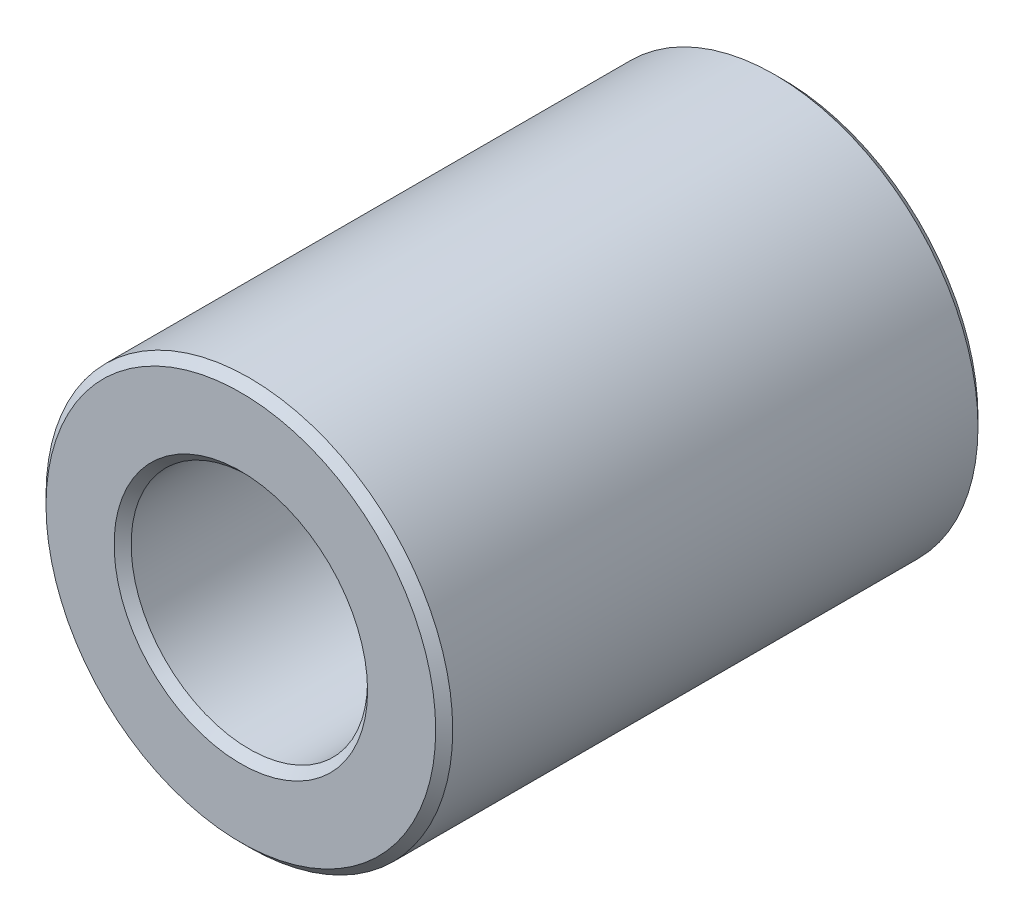
from build123d import *

# Parameters (mm, degrees)
BOSS_EXTRUDE1_DEPTH      = 6.35
BOSS_EXTRUDE1_DEPTH_BACK = 6.35
SKETCH3_R                = 4.7625
SKETCH3_R_2              = 2.7686
CHAMFER1_SIZE            = 0.19939


with BuildPart() as part:
    # Sketch3 → Boss-Extrude1 (new, two sides: drawn at the far end of the back side and taken through both)
    with BuildSketch(Plane.XY.offset(-BOSS_EXTRUDE1_DEPTH_BACK)):
        Circle(SKETCH3_R)
        Circle(SKETCH3_R_2, mode=Mode.SUBTRACT)
    extrude(amount=BOSS_EXTRUDE1_DEPTH + BOSS_EXTRUDE1_DEPTH_BACK)

    # Chamfer1
    chamfer1_edges = [part.edges().sort_by_distance(p)[0] for p in [
        (-4.7625, 0, -6.35),
        (-2.7686, 0, -6.35),
        (-4.7625, 0, 6.35),
        (-2.7686, 0, 6.35),
    ]]
    chamfer(chamfer1_edges, length=CHAMFER1_SIZE)


solid = part.part
